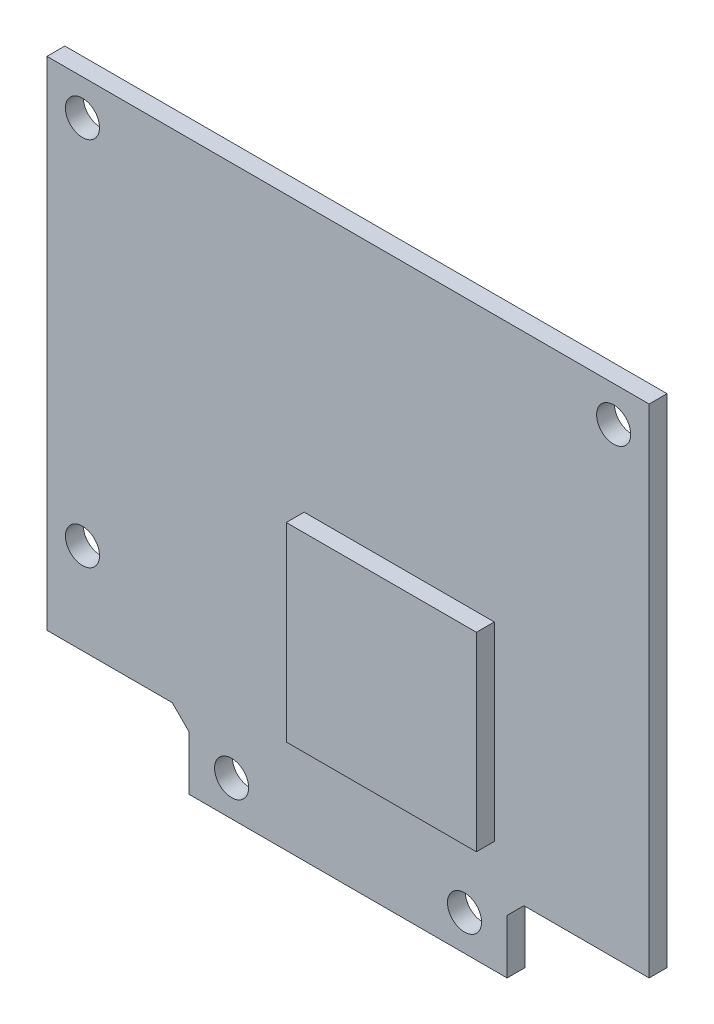
from build123d import *

# Parameters (mm, degrees)
EXTRUDE1_DEPTH = 1.6
SKETCH2_R      = 1.524
EXTRUDE2_DEPTH = 2.6
SKETCH4_W      = 17
SKETCH4_H      = 17
EXTRUDE3_DEPTH = 1.6


with BuildPart() as part:
    # Sketch1 → Extrude1 (new body)
    with BuildSketch(Plane.XY):
        Polygon((15.724, -33.91), (26.924, -33.91), (26.924, 10.54), (-26.924, 10.54), (-26.924, -33.91), (-15.724, -33.91), (-14.224, -35.41), (-14.224, -40.26), (14.224, -40.26), (14.224, -35.41), align=None)
    extrude(amount=EXTRUDE1_DEPTH)

    # Sketch2 → Extrude2 (cut, through all)
    with BuildSketch(Plane.XY):
        with Locations((23.749, 7.365)):
            Circle(SKETCH2_R)
        with Locations((10.414, -37.085)):
            Circle(SKETCH2_R)
        with Locations((-10.414, -37.085)):
            Circle(SKETCH2_R)
        with Locations((-23.749, -25.782)):
            Circle(SKETCH2_R)
        with Locations((-23.749, 7.365)):
            Circle(SKETCH2_R)
    extrude(amount=EXTRUDE2_DEPTH, mode=Mode.SUBTRACT)

    # Sketch4 → Extrude3 (add)
    with BuildSketch(Plane.XY.offset(1.6)):
        with Locations((4.576, -21.76)):
            Rectangle(SKETCH4_W, SKETCH4_H)
    extrude(amount=EXTRUDE3_DEPTH)


solid = part.part
